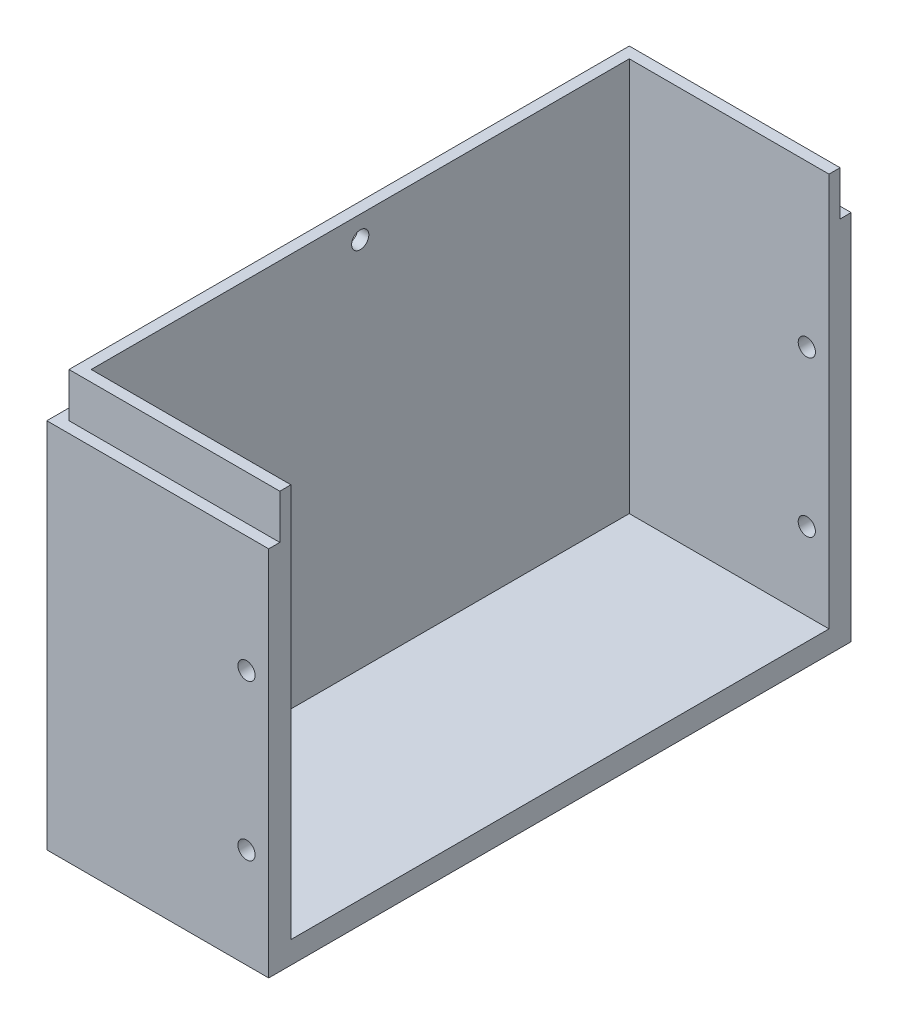
from build123d import *

# Parameters (mm, degrees)
SKETCH1_W               = 40
SKETCH1_H               = 105
BOSS_EXTRUDE3_DEPTH     = 75
SKETCH4_W               = 97
SKETCH4_H               = 71
CUT_EXTRUDE2_DEPTH      = 36
SKETCH5_W               = 40
SKETCH5_H               = 8
CUT_EXTRUDE3_DEPTH      = 2
SKETCH6_W               = 40
SKETCH6_H               = 8
CUT_EXTRUDE4_DEPTH      = 2
SKETCH7_W               = 101
SKETCH7_H               = 8
CUT_EXTRUDE5_DEPTH      = 2
SKETCH8_R               = 1.55
CUT_EXTRUDE6_DEPTH      = 102
CUT_EXTRUDE6_DEPTH_BACK = 5
SKETCH10_R              = 1.55
CUT_EXTRUDE8_DEPTH      = 2


with BuildPart() as part:
    # Sketch1 → Boss-Extrude3 (new body)
    with BuildSketch(Plane(origin=(0, 0, 0), x_dir=(1, 0, 0), z_dir=(0, 1, 0))):
        Rectangle(SKETCH1_W, SKETCH1_H)
    extrude(amount=BOSS_EXTRUDE3_DEPTH)

    # Sketch4 → Cut-Extrude2 (cut)
    with BuildSketch(Plane(origin=(20, 0, 0), x_dir=(0, 0, -1), z_dir=(1, 0, 0))):
        with Locations((0, 39.5)):
            Rectangle(SKETCH4_W, SKETCH4_H)
    extrude(amount=-CUT_EXTRUDE2_DEPTH, mode=Mode.SUBTRACT)

    # Sketch5 → Cut-Extrude3 (cut)
    with BuildSketch(Plane.XY.offset(52.5)):
        with Locations((0, 71)):
            Rectangle(SKETCH5_W, SKETCH5_H)
    extrude(amount=-CUT_EXTRUDE3_DEPTH, mode=Mode.SUBTRACT)

    # Sketch6 → Cut-Extrude4 (cut)
    with BuildSketch(Plane(origin=(0, 0, -52.5), x_dir=(-1, 0, 0), z_dir=(0, 0, -1))):
        with Locations((0, 71)):
            Rectangle(SKETCH6_W, SKETCH6_H)
    extrude(amount=-CUT_EXTRUDE4_DEPTH, mode=Mode.SUBTRACT)

    # Sketch7 → Cut-Extrude5 (cut)
    with BuildSketch(Plane.ZY.offset(20)):
        with Locations((0, 71)):
            Rectangle(SKETCH7_W, SKETCH7_H)
    extrude(amount=-CUT_EXTRUDE5_DEPTH, mode=Mode.SUBTRACT)

    # Sketch8 → Cut-Extrude6 (cut, two sides)
    with BuildSketch(Plane(origin=(0, 0, 48.5), x_dir=(-1, 0, 0), z_dir=(0, 0, -1))) as cut_extrude6_sk:
        with Locations((-16, 18)):
            Circle(SKETCH8_R)
        with Locations((-16, 46)):
            Circle(SKETCH8_R)
    extrude(amount=CUT_EXTRUDE6_DEPTH, mode=Mode.SUBTRACT)
    extrude(cut_extrude6_sk.sketch, amount=-CUT_EXTRUDE6_DEPTH_BACK, mode=Mode.SUBTRACT)

    # Sketch10 → Cut-Extrude8 (cut)
    with BuildSketch(Plane.ZY.offset(18)):
        with Locations((0, 71)):
            Circle(SKETCH10_R)
    extrude(amount=-CUT_EXTRUDE8_DEPTH, mode=Mode.SUBTRACT)


solid = part.part
